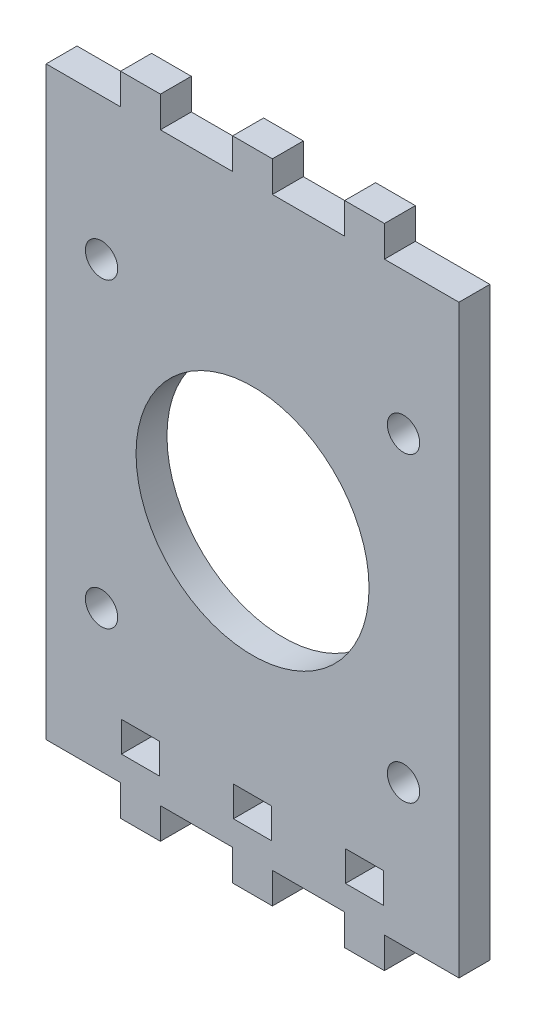
from build123d import *

# Parameters (mm, degrees)
SKETCH1_R           = 1.7
SKETCH1_W           = 4
SKETCH1_H           = 3.175
SKETCH1_R_2         = 12
BOSS_EXTRUDE1_DEPTH = 3.175
SKETCH2_R           = 11.95936
SKETCH2_R_2         = 1.65936
SKETCH2_W           = 3.91872
SKETCH2_H           = 3.09372
BOSS_EXTRUDE2_DEPTH = 3.175


with BuildPart() as part:
    # Sketch1 → Boss-Extrude1 (new body)
    with BuildSketch(Plane.XY):
        Polygon((2, -33.175), (2, -30), (9.5, -30), (9.5, -33.175), (13.5, -33.175), (13.5, -30), (21.15, -30), (21.15, 30), (13.5, 30), (13.5, 33.175), (9.5, 33.175), (9.5, 30), (2, 30), (2, 33.175), (-2, 33.175), (-2, 30), (-9.5, 30), (-9.5, 33.175), (-13.5, 33.175), (-13.5, 30), (-21.15, 30), (-21.15, -30), (-13.5, -30), (-13.5, -33.175), (-9.5, -33.175), (-9.5, -30), (-2, -30), (-2, -33.175), align=None)
        with Locations((15.5, 15.5)):
            Circle(SKETCH1_R, mode=Mode.SUBTRACT)
        with Locations((-11.5, -25.9125)):
            Rectangle(SKETCH1_W, SKETCH1_H, mode=Mode.SUBTRACT)
        with Locations((0, -25.9125)):
            Rectangle(SKETCH1_W, SKETCH1_H, mode=Mode.SUBTRACT)
        with Locations((-15.5, -15.5)):
            Circle(SKETCH1_R, mode=Mode.SUBTRACT)
        with Locations((11.5, -25.9125)):
            Rectangle(SKETCH1_W, SKETCH1_H, mode=Mode.SUBTRACT)
        with Locations((15.5, -15.5)):
            Circle(SKETCH1_R, mode=Mode.SUBTRACT)
        with Locations((-15.5, 15.5)):
            Circle(SKETCH1_R, mode=Mode.SUBTRACT)
        Circle(SKETCH1_R_2, mode=Mode.SUBTRACT)
    extrude(amount=BOSS_EXTRUDE1_DEPTH)

    # Sketch2 → Boss-Extrude2 (add)
    with BuildSketch(Plane.XY.offset(3.175)):
        Polygon((-21.19064, 30.04064), (-21.19064, -30.04064), (-13.54064, -30.04064), (-13.54064, -33.21564), (-9.45936, -33.21564), (-9.45936, -30.04064), (-2.04064, -30.04064), (-2.04064, -33.21564), (2.04064, -33.21564), (2.04064, -30.04064), (9.45936, -30.04064), (9.45936, -33.21564), (13.54064, -33.21564), (13.54064, -30.04064), (21.19064, -30.04064), (21.19064, 30.04064), (13.54064, 30.04064), (13.54064, 33.21564), (9.45936, 33.21564), (9.45936, 30.04064), (2.04064, 30.04064), (2.04064, 33.21564), (-2.04064, 33.21564), (-2.04064, 30.04064), (-9.45936, 30.04064), (-9.45936, 33.21564), (-13.54064, 33.21564), (-13.54064, 30.04064), align=None)
        Circle(SKETCH2_R, mode=Mode.SUBTRACT)
        with Locations((-15.5, -15.5)):
            Circle(SKETCH2_R_2, mode=Mode.SUBTRACT)
        with Locations((15.5, -15.5)):
            Circle(SKETCH2_R_2, mode=Mode.SUBTRACT)
        with Locations((15.5, 15.5)):
            Circle(SKETCH2_R_2, mode=Mode.SUBTRACT)
        with Locations((-15.5, 15.5)):
            Circle(SKETCH2_R_2, mode=Mode.SUBTRACT)
        with Locations((11.5, -25.9125)):
            Rectangle(SKETCH2_W, SKETCH2_H, mode=Mode.SUBTRACT)
        with Locations((0, -25.9125)):
            Rectangle(SKETCH2_W, SKETCH2_H, mode=Mode.SUBTRACT)
        with Locations((-11.5, -25.9125)):
            Rectangle(SKETCH2_W, SKETCH2_H, mode=Mode.SUBTRACT)
    extrude(amount=-BOSS_EXTRUDE2_DEPTH)


solid = part.part
